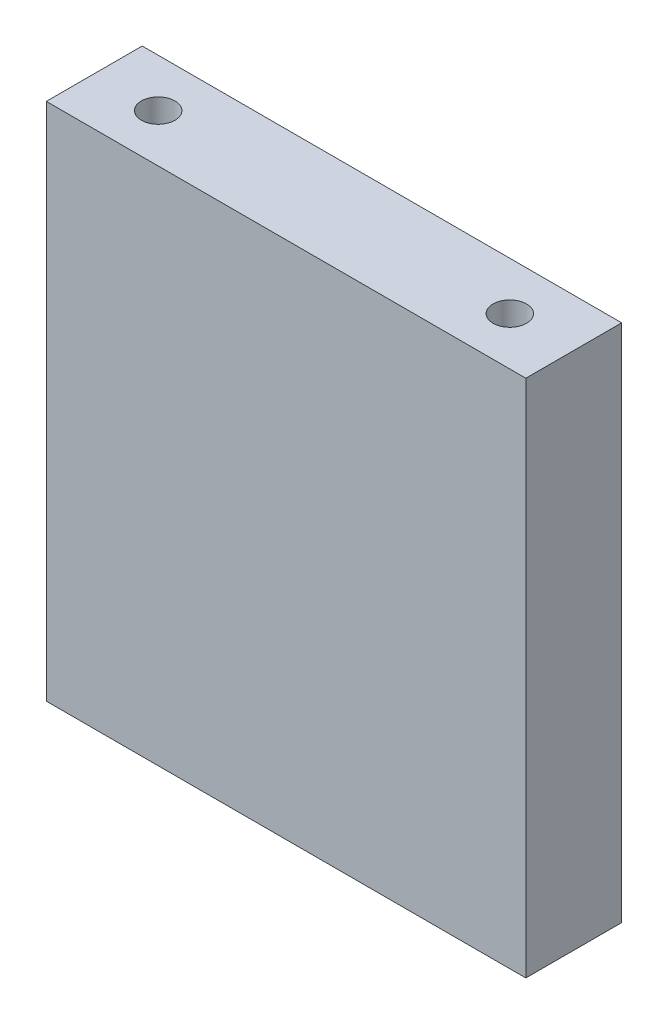
from build123d import *

# Parameters (mm, degrees)
ESQUISSE1_W           = 60
ESQUISSE1_H           = 65
BOSS_EXTRU_1_DEPTH    = 12
TROU_TARAUD_M57_D     = 4.2
TROU_TARAUD_M57_DEPTH = 14
TROU_TARAUD_M57_TIP   = 1.2618073
TROU_TARAUD_M58_D     = 4.2
TROU_TARAUD_M58_DEPTH = 14
TROU_TARAUD_M58_TIP   = 1.2618073
TROU_TARAUD_M56_D     = 4.2
TROU_TARAUD_M56_DEPTH = 14
TROU_TARAUD_M56_TIP   = 1.2618073
TROU_TARAUD_M55_D     = 4.2
TROU_TARAUD_M55_DEPTH = 14
TROU_TARAUD_M55_TIP   = 1.2618073


with BuildPart() as part:
    # Esquisse1 → Boss.-Extru.1 (new body)
    with BuildSketch(Plane.XY):
        with Locations((30, 32.5)):
            Rectangle(ESQUISSE1_W, ESQUISSE1_H)
    extrude(amount=BOSS_EXTRU_1_DEPTH)

    # Trou taraudé M57
    with Locations(Plane(origin=(0, 65, 0), x_dir=(-1, 0, 0), z_dir=(0, 1, 0))):
        with Locations((-8, 6)):
            Hole(TROU_TARAUD_M57_D / 2, depth=TROU_TARAUD_M57_DEPTH)
            with Locations((0, 0, -(TROU_TARAUD_M57_DEPTH + TROU_TARAUD_M57_TIP / 2))):  # 118° drill point
                Cone(0, TROU_TARAUD_M57_D / 2, TROU_TARAUD_M57_TIP, mode=Mode.SUBTRACT)

    # Trou taraudé M58
    with Locations(Plane(origin=(0, 65, 0), x_dir=(-1, 0, 0), z_dir=(0, 1, 0))):
        with Locations((-52, 6)):
            Hole(TROU_TARAUD_M58_D / 2, depth=TROU_TARAUD_M58_DEPTH)
            with Locations((0, 0, -(TROU_TARAUD_M58_DEPTH + TROU_TARAUD_M58_TIP / 2))):  # 118° drill point
                Cone(0, TROU_TARAUD_M58_D / 2, TROU_TARAUD_M58_TIP, mode=Mode.SUBTRACT)

    # Trou taraudé M56
    with Locations(Plane.XZ):
        with Locations((8, 6)):
            Hole(TROU_TARAUD_M56_D / 2, depth=TROU_TARAUD_M56_DEPTH)
            with Locations((0, 0, -(TROU_TARAUD_M56_DEPTH + TROU_TARAUD_M56_TIP / 2))):  # 118° drill point
                Cone(0, TROU_TARAUD_M56_D / 2, TROU_TARAUD_M56_TIP, mode=Mode.SUBTRACT)

    # Trou taraudé M55
    with Locations(Plane.XZ):
        with Locations((52, 6)):
            Hole(TROU_TARAUD_M55_D / 2, depth=TROU_TARAUD_M55_DEPTH)
            with Locations((0, 0, -(TROU_TARAUD_M55_DEPTH + TROU_TARAUD_M55_TIP / 2))):  # 118° drill point
                Cone(0, TROU_TARAUD_M55_D / 2, TROU_TARAUD_M55_TIP, mode=Mode.SUBTRACT)


solid = part.part
